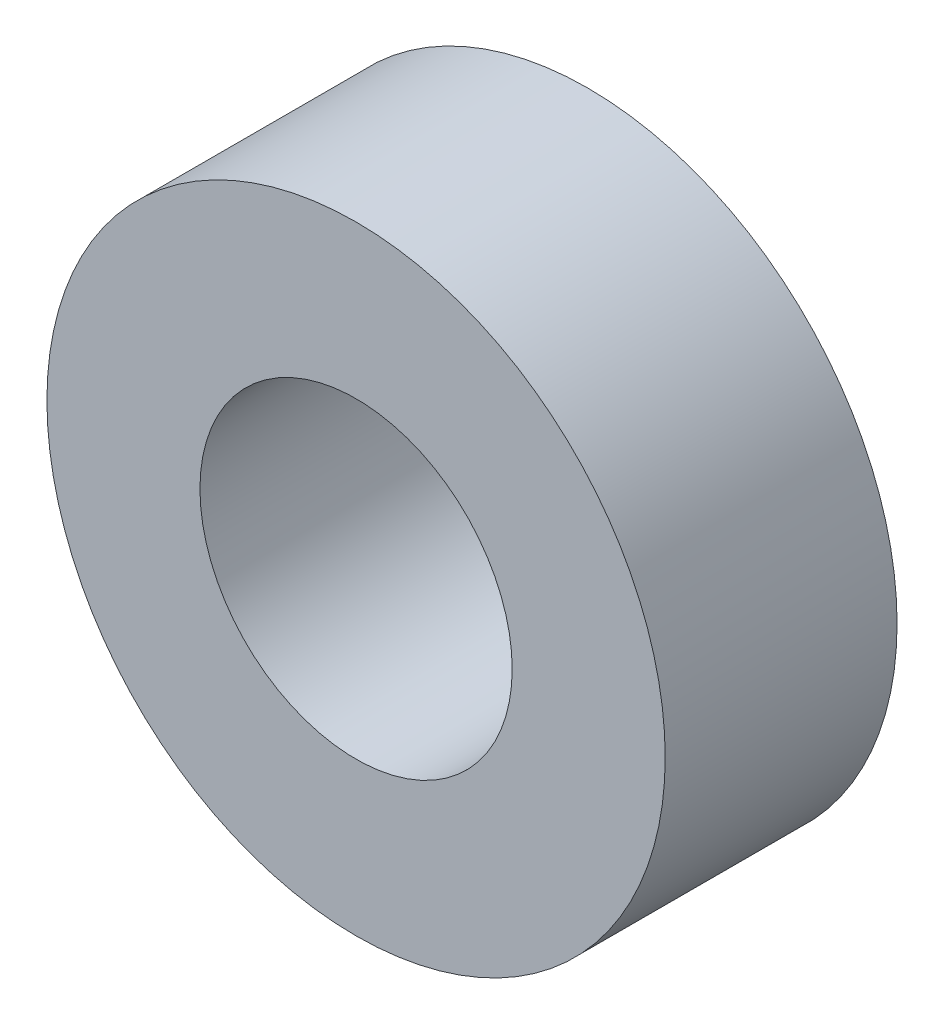
from build123d import *

# Parameters (mm, degrees)
SKETCH1_R      = 12.7
SKETCH1_R_2    = 6.4135
EXTRUDE1_DEPTH = 4.7625


with BuildPart() as part:
    # Sketch1 → Extrude1 (new body, symmetric)
    with BuildSketch(Plane.XY):
        Circle(SKETCH1_R)
        Circle(SKETCH1_R_2, mode=Mode.SUBTRACT)
    extrude(amount=EXTRUDE1_DEPTH, both=True)


solid = part.part
